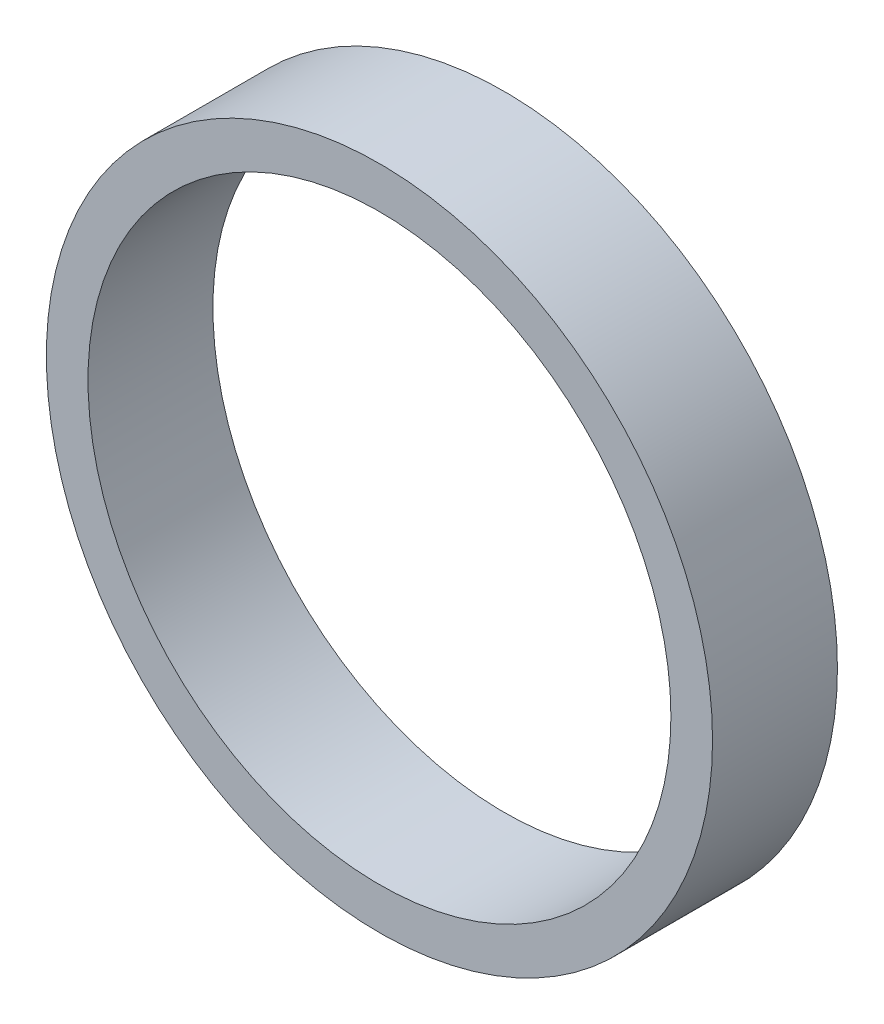
from build123d import *

# Parameters (mm, degrees)
SKETCH_1_R      = 16
SKETCH_1_R_2    = 14
EXTRUDE_1_DEPTH = 6


with BuildPart() as part:
    # 草图1 → 凸台-拉伸1 (new body)
    with BuildSketch(Plane.XY):
        Circle(SKETCH_1_R)
        Circle(SKETCH_1_R_2, mode=Mode.SUBTRACT)
    extrude(amount=EXTRUDE_1_DEPTH)


solid = part.part
